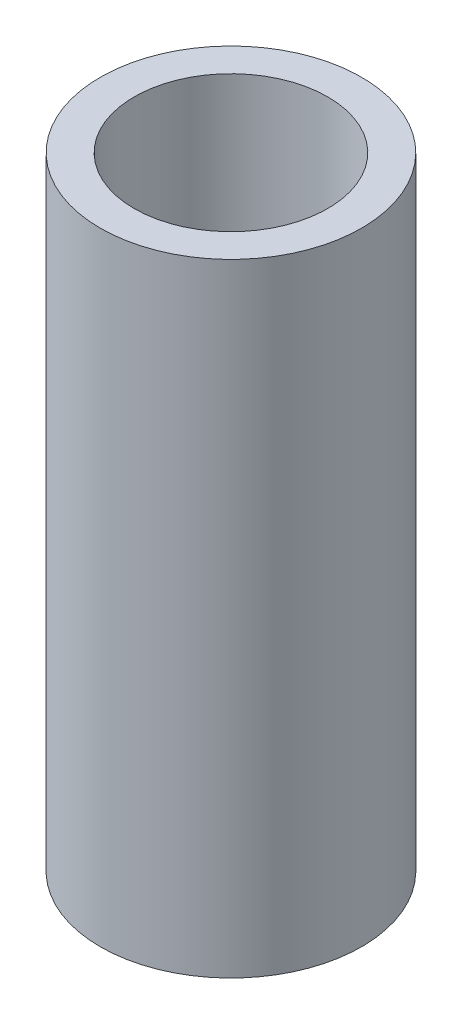
from build123d import *

# Parameters (mm, degrees)
SKETCH1_R           = 10.668
SKETCH1_R_2         = 7.8994
BOSS_EXTRUDE1_DEPTH = 50.8


with BuildPart() as part:
    # Sketch1 → Boss-Extrude1 (new body)
    with BuildSketch(Plane(origin=(0, 0, 0), x_dir=(1, 0, 0), z_dir=(0, 1, 0))):
        Circle(SKETCH1_R)
        Circle(SKETCH1_R_2, mode=Mode.SUBTRACT)
    extrude(amount=BOSS_EXTRUDE1_DEPTH)


solid = part.part
